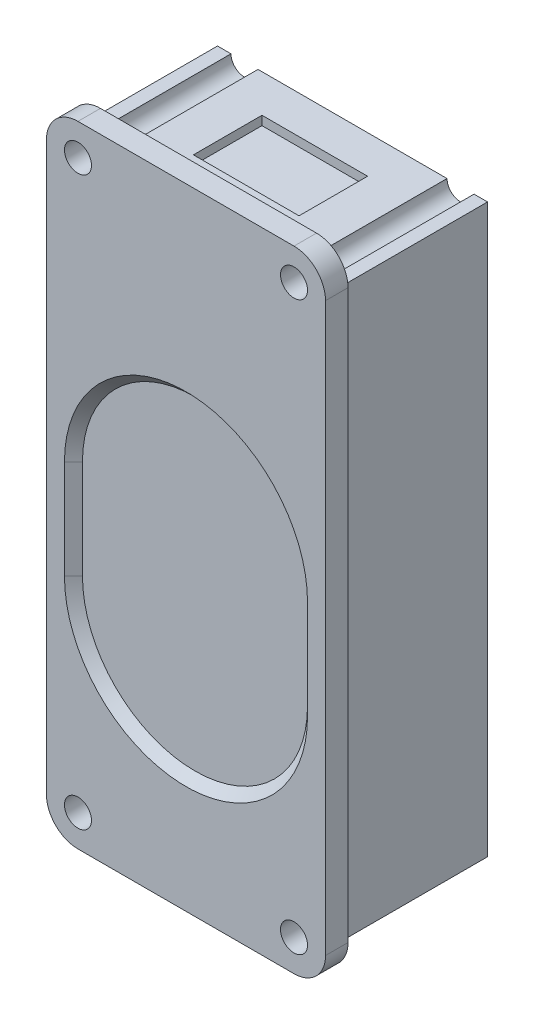
from build123d import *

# Parameters (mm, degrees)
BOSS_EXTRUDE1_DEPTH     = 2.5
SKETCH3_W               = 16
SKETCH3_H               = 63
BOSS_EXTRUDE2_DEPTH     = 15
SKETCH2_R               = 1.5
CUT_EXTRUDE1_DEPTH      = 3.5
CUT_EXTRUDE1_DEPTH_BACK = 17
CUT_EXTRUDE2_DEPTH      = 1
CUT_EXTRUDE2_TAPER      = 45
SKETCH5_W               = 11.73250701
SKETCH5_H               = 7.616061756
CUT_EXTRUDE3_DEPTH      = 1


with BuildPart() as part:
    # Sketch1 → Boss-Extrude1 (new body)
    with BuildSketch(Plane.XY):
        with BuildLine():
            Line((-12, 35), (12, 35))
            ThreePointArc((12, 35), (14.474873734, 33.974873734), (15.5, 31.5))
            Line((15.5, 31.5), (15.5, -31.5))
            ThreePointArc((15.5, -31.5), (14.474873734, -33.974873734), (12, -35))
            Line((12, -35), (-12, -35))
            ThreePointArc((-12, -35), (-14.474873734, -33.974873734), (-15.5, -31.5))
            Line((-15.5, -31.5), (-15.5, 31.5))
            ThreePointArc((-15.5, 31.5), (-14.474873734, 33.974873734), (-12, 35))
        make_face()
    extrude(amount=BOSS_EXTRUDE1_DEPTH)

    # Sketch3 → Boss-Extrude2 (add, symmetric)
    with BuildSketch(Plane(origin=(0, 0, 0), x_dir=(0, 0, -1), z_dir=(1, 0, 0))):
        with Locations((8, 0)):
            Rectangle(SKETCH3_W, SKETCH3_H)
    extrude(amount=BOSS_EXTRUDE2_DEPTH, both=True)

    # Sketch2 → Cut-Extrude1 (cut, two sides)
    with BuildSketch(Plane.XY) as cut_extrude1_sk:
        with Locations((-12, -31.5)):
            Circle(SKETCH2_R)
        with Locations((12, -31.5)):
            Circle(SKETCH2_R)
        with Locations((12, 31.5)):
            Circle(SKETCH2_R)
        with Locations((-12, 31.5)):
            Circle(SKETCH2_R)
    extrude(amount=CUT_EXTRUDE1_DEPTH, mode=Mode.SUBTRACT)
    extrude(cut_extrude1_sk.sketch, amount=-CUT_EXTRUDE1_DEPTH_BACK, mode=Mode.SUBTRACT)

    # Sketch4 → Cut-Extrude2 (cut)
    with BuildSketch(Plane.XY.offset(2.5)):
        with BuildLine():
            ThreePointArc((13.5, 1.5), (0, 15), (-13.5, 1.5))
            Line((-13.5, 1.5), (-13.5, -9.5))
            ThreePointArc((-13.5, -9.5), (0, -23), (13.5, -9.5))
            Line((13.5, -9.5), (13.5, 1.5))
        make_face()
    extrude(amount=-CUT_EXTRUDE2_DEPTH, taper=CUT_EXTRUDE2_TAPER, mode=Mode.SUBTRACT)

    # Sketch5 → Cut-Extrude3 (cut)
    with BuildSketch(Plane(origin=(0, 31.5, 0), x_dir=(1, 0, 0), z_dir=(0, 1, 0))):
        with Locations((0, 8)):
            Rectangle(SKETCH5_W, SKETCH5_H)
    extrude(amount=-CUT_EXTRUDE3_DEPTH, mode=Mode.SUBTRACT)


solid = part.part
